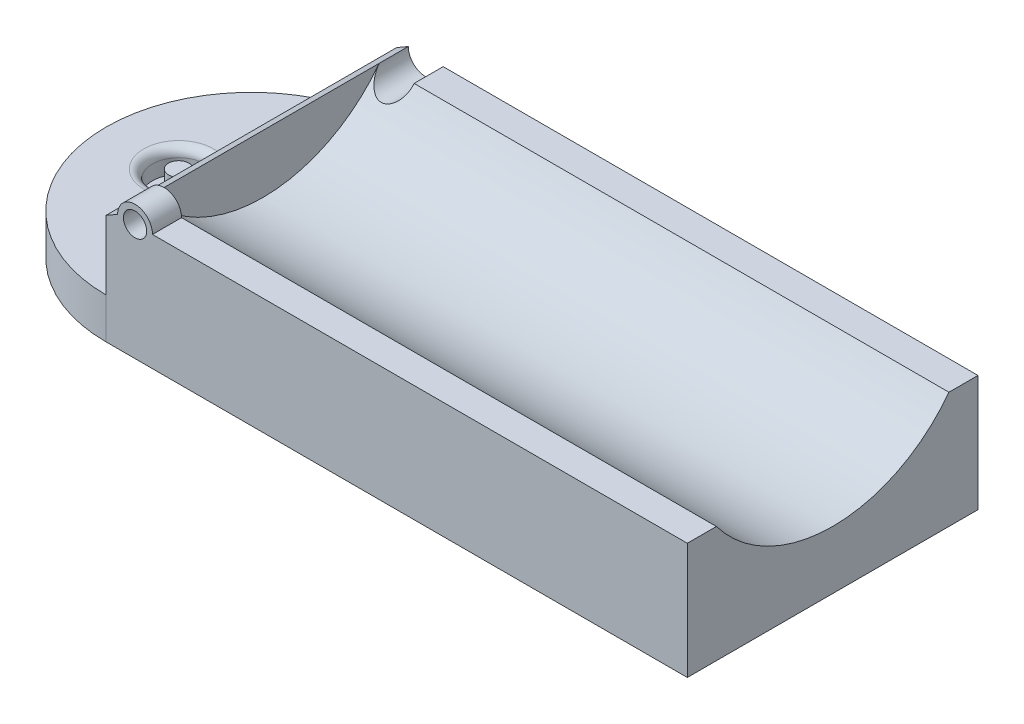
from build123d import *

# Parameters (mm, degrees)
SKETCH1_W           = 100
SKETCH1_H           = 50
BOSS_EXTRUDE1_DEPTH = 20
SKETCH4_W           = 25
SKETCH4_H           = 7
CUT_EXTRUDE1_DEPTH  = 100
SKETCH5_R           = 4.5
SKETCH5_R_2         = 1.75
CUT_EXTRUDE2_DEPTH  = 4
FILLET2_R           = 1.5
SKETCH6_R           = 3
SKETCH6_R_2         = 2
BOSS_EXTRUDE3_DEPTH = 5
CUT_EXTRUDE3_DEPTH  = 10
SKETCH10_R          = 3
CUT_EXTRUDE4_DEPTH  = 10
CUT_EXTRUDE5_DEPTH  = 54
BOSS_EXTRUDE4_DEPTH = 50


with BuildPart() as part:
    # Sketch1 → Boss-Extrude1 (new body)
    with BuildSketch(Plane(origin=(0, 0, 0), x_dir=(1, 0, 0), z_dir=(0, 1, 0))):
        with Locations((50, 25)):
            Rectangle(SKETCH1_W, SKETCH1_H)
    extrude(amount=BOSS_EXTRUDE1_DEPTH)

    # Sketch4 → Revolve1 (revolve)
    with BuildSketch(Plane.ZY):
        with Locations((-12.5, 3.5)):
            Rectangle(SKETCH4_W, SKETCH4_H)
    revolve(axis=Axis((0, 0, -25), (0, 1, 0)))

    # Sketch2 → Cut-Extrude1 (cut)
    with BuildSketch(Plane(origin=(100, 0, 0), x_dir=(0, 0, -1), z_dir=(1, 0, 0))):
        with BuildLine():
            Line((45, 20), (5, 20))
            ThreePointArc((5, 20), (25, 10), (45, 20))
        make_face()
    extrude(amount=-CUT_EXTRUDE1_DEPTH, mode=Mode.SUBTRACT)

    # Sketch5 → Cut-Extrude2 (cut)
    with BuildSketch(Plane(origin=(0, 7, 0), x_dir=(1, 0, 0), z_dir=(0, 1, 0))):
        with Locations((-12.5, 25)):
            Circle(SKETCH5_R)
        with Locations((-12.5, 25)):
            Circle(SKETCH5_R_2, mode=Mode.SUBTRACT)
    extrude(amount=-CUT_EXTRUDE2_DEPTH, mode=Mode.SUBTRACT)

    # Fillet2
    fillet2_edges = [part.edges().sort_by_distance(p)[0] for p in [
        (-17, 7, -25),
    ]]
    fillet(fillet2_edges, radius=FILLET2_R)

    # Sketch6 → Boss-Extrude3 (add)
    with BuildSketch(Plane.XY):
        with Locations((5, 20)):
            Circle(SKETCH6_R)
        with Locations((5, 20)):
            Circle(SKETCH6_R_2, mode=Mode.SUBTRACT)
    extrude(amount=-BOSS_EXTRUDE3_DEPTH)

    # Sketch8 → Cut-Extrude3 (cut)
    with BuildSketch(Plane.XY):
        with BuildLine():
            Line((3, 20), (7, 20))
            ThreePointArc((7, 20), (5, 18), (3, 20))
        make_face()
    extrude(amount=-CUT_EXTRUDE3_DEPTH, mode=Mode.SUBTRACT)

    # Sketch10 → Cut-Extrude4 (cut)
    with BuildSketch(Plane(origin=(0, 0, -50), x_dir=(-1, 0, 0), z_dir=(0, 0, -1))):
        with Locations((-5, 20)):
            Circle(SKETCH10_R)
    extrude(amount=-CUT_EXTRUDE4_DEPTH, mode=Mode.SUBTRACT)

    # Sketch11 → Cut-Extrude5 (cut)
    with BuildSketch(Plane(origin=(0, 0, -50), x_dir=(-1, 0, 0), z_dir=(0, 0, -1))):
        Polygon((-2, 20), (0, 18.845299462), (0, 20), align=None)
    extrude(amount=-CUT_EXTRUDE5_DEPTH, mode=Mode.SUBTRACT)

    # Sketch12 → Boss-Extrude4 (add)
    with BuildSketch(Plane(origin=(0, 0, -50), x_dir=(-1, 0, 0), z_dir=(0, 0, -1))):
        Polygon((-2, 20), (-2, 0), (0, 0), (0, 18.845299462), align=None)
    extrude(amount=-BOSS_EXTRUDE4_DEPTH)


solid = part.part
